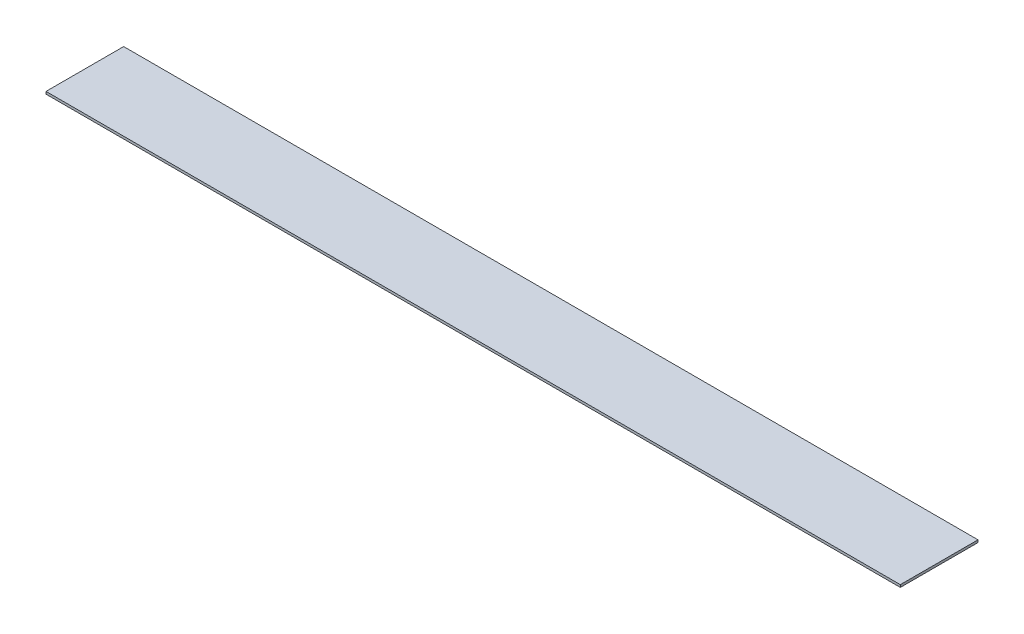
from build123d import *

# Parameters (mm, degrees)
SKETCH1_W           = 558.8
SKETCH1_H           = 50.8
BOSS_EXTRUDE1_DEPTH = 1.5875


with BuildPart() as part:
    # Sketch1 → Boss-Extrude1 (new body)
    with BuildSketch(Plane.XZ.offset(80.26236602)):
        with Locations((279.4, 25.4)):
            Rectangle(SKETCH1_W, SKETCH1_H)
    extrude(amount=BOSS_EXTRUDE1_DEPTH)


solid = part.part
